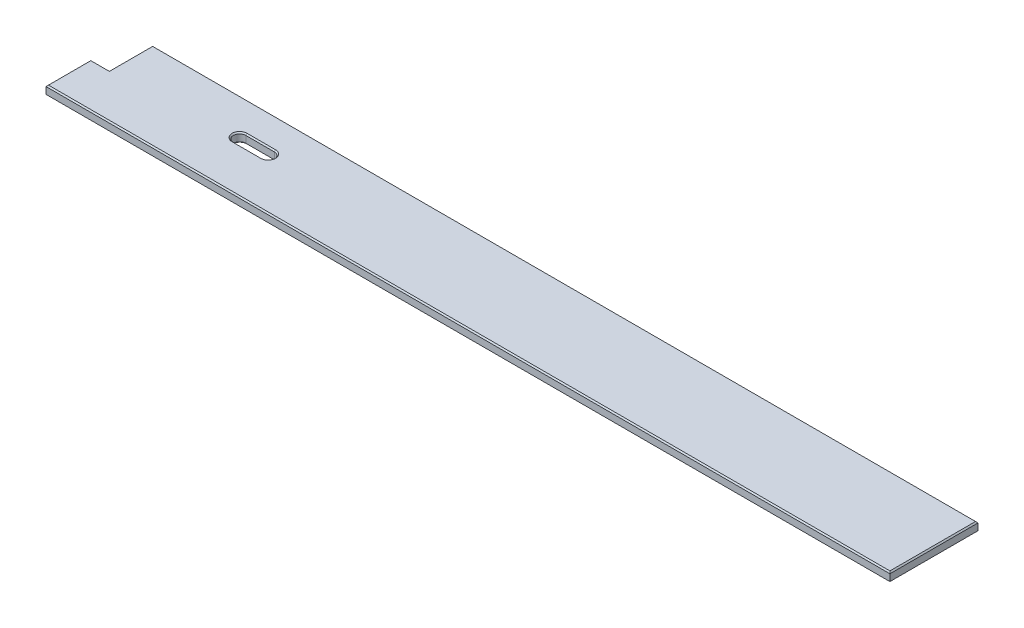
from build123d import *

# Parameters (mm, degrees)
SKETCH1_W           = 1695.45
SKETCH1_H           = 180.975
BOSS_EXTRUDE1_DEPTH = 19.05
SKETCH2_W           = 38.1
SKETCH2_H           = 92.075
BOSS_EXTRUDE3_DEPTH = 19.05
CHAMFER1_SIZE       = 2.54
CHAMFER2_SIZE       = 2.54


with BuildPart() as part:
    # Sketch1 → Boss-Extrude1 (new body)
    with BuildSketch(Plane(origin=(0, 0, 0), x_dir=(1, 0, 0), z_dir=(0, 1, 0))):
        with Locations((847.725, 90.4875)):
            Rectangle(SKETCH1_W, SKETCH1_H)
        with BuildLine():
            Line((254, 118.25605), (312.7502, 118.25605))
            ThreePointArc((312.7502, 118.25605), (325.4502, 105.55605), (312.7502, 92.85605))
            Line((312.7502, 92.85605), (254, 92.85605))
            ThreePointArc((254, 92.85605), (241.3, 105.55605), (254, 118.25605))
        make_face(mode=Mode.SUBTRACT)
    extrude(amount=BOSS_EXTRUDE1_DEPTH)

    # Sketch2 → Boss-Extrude3 (add, through all)
    with BuildSketch(Plane(origin=(0, 19.05, 0), x_dir=(1, 0, 0), z_dir=(0, 1, 0))):
        with Locations((-19.05, 46.0375)):
            Rectangle(SKETCH2_W, SKETCH2_H)
    extrude(amount=-BOSS_EXTRUDE3_DEPTH)

    # Chamfer1
    chamfer1_edges = [part.edges().sort_by_distance(p)[0] for p in [
        (1695.45, 19.05, -90.4875),
        (325.4502, 19.05, -105.55605),
        (847.725, 19.05, -180.975),
        (283.3751, 19.05, -118.25605),
        (241.3, 19.05, -105.55605),
        (283.3751, 19.05, -92.85605),
        (-19.05, 19.05, -92.075),
        (-38.1, 19.05, -46.0375),
        (0, 19.05, -136.525),
        (828.675, 19.05, 0),
    ]]
    chamfer(chamfer1_edges, length=CHAMFER1_SIZE)

    # Chamfer2
    chamfer2_edges = [part.edges().sort_by_distance(p)[0] for p in [
        (325.4502, 0, -105.55605),
        (283.3751, 0, -118.25605),
        (241.3, 0, -105.55605),
        (283.3751, 0, -92.85605),
        (-38.1, 0, -46.0375),
        (-19.05, 0, -92.075),
        (847.725, 0, -180.975),
        (1695.45, 0, -90.4875),
        (828.675, 0, 0),
        (0, 0, -136.525),
    ]]
    chamfer(chamfer2_edges, length=CHAMFER2_SIZE)


solid = part.part
